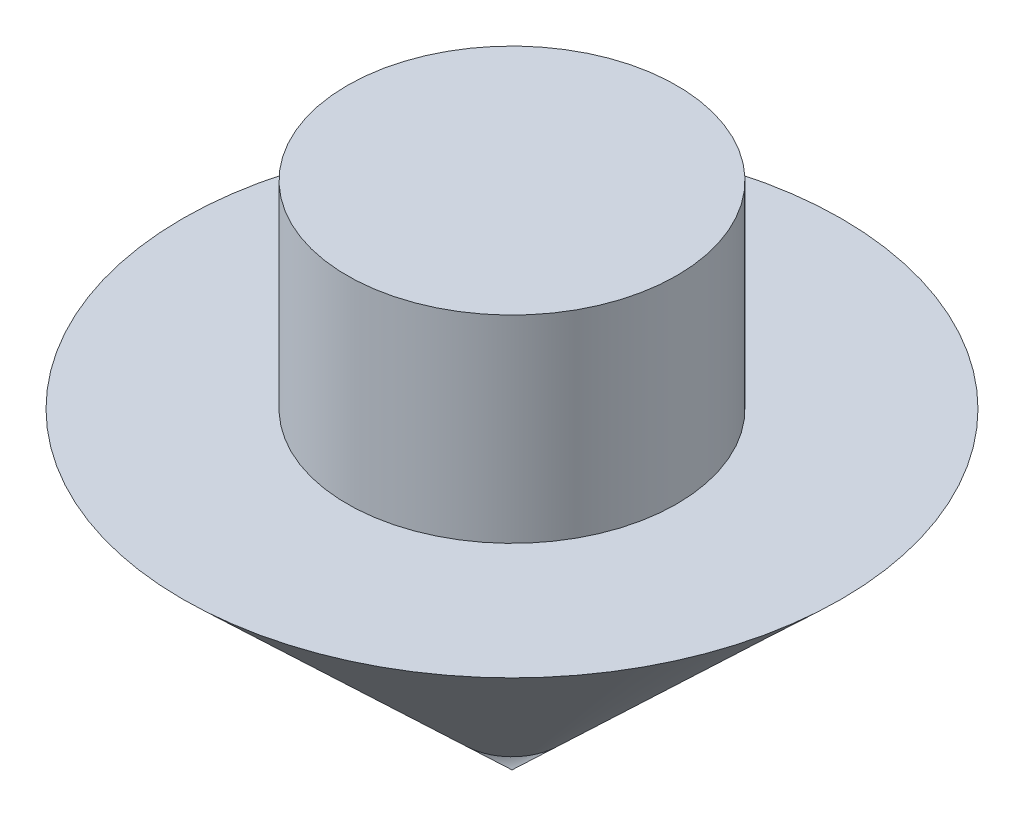
from build123d import *

# Parameters (mm, degrees)
SKETCH2_W = 5
SKETCH2_H = 6


with BuildPart() as part:
    # Sketch1 → Revolve1 (revolve)
    with BuildSketch(Plane.XY):
        Polygon((0, 9.489645667), (0, 0), (10, 9.489645667), align=None)
    revolve(axis=Axis((0, 0, 0), (0, 1, 0)))

    # Sketch2 → Revolve2 (revolve)
    with BuildSketch(Plane.XY):
        with Locations((2.5, 12.489645667)):
            Rectangle(SKETCH2_W, SKETCH2_H)
    revolve(axis=Axis((0, 0, 0), (0, 1, 0)))


solid = part.part
